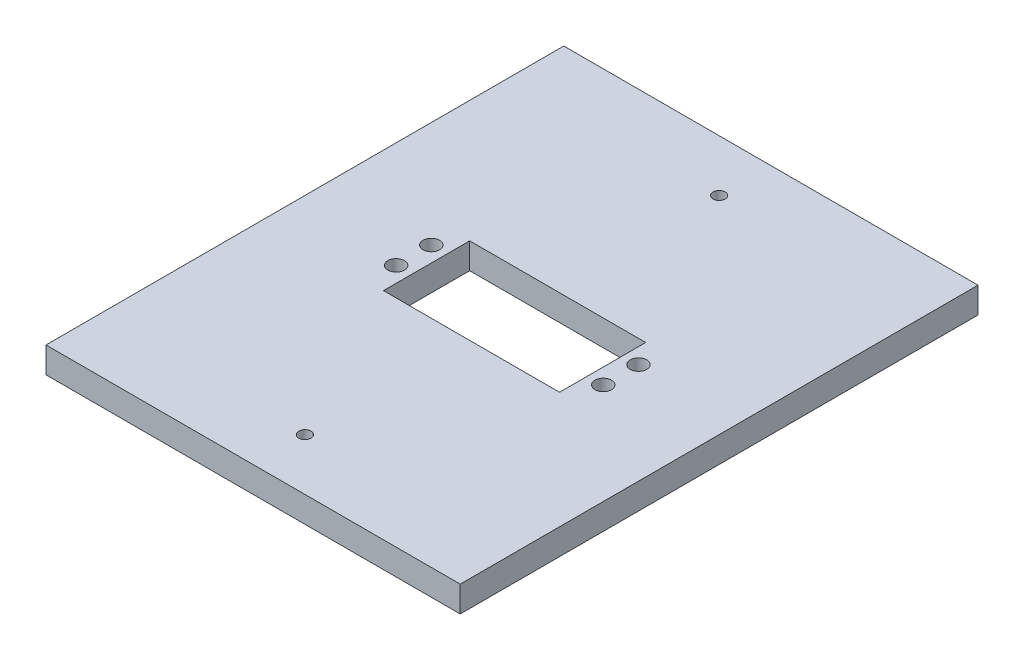
from build123d import *

# Parameters (mm, degrees)
SKETCH1_W           = 101.6
SKETCH1_H           = 127
BOSS_EXTRUDE1_DEPTH = 6.35
SKETCH2_R           = 2.032
SKETCH2_W           = 43.18
SKETCH2_H           = 21.1455
CUT_EXTRUDE1_DEPTH  = 7.35
SKETCH7_R           = 1.5
CUT_EXTRUDE2_DEPTH  = 7.35


with BuildPart() as part:
    # Sketch1 → Boss-Extrude1 (new body)
    with BuildSketch(Plane(origin=(0, 0, 0), x_dir=(1, 0, 0), z_dir=(0, 1, 0))):
        with Locations((134.62, 120.65)):
            Rectangle(SKETCH1_W, SKETCH1_H)
    extrude(amount=BOSS_EXTRUDE1_DEPTH)

    # Sketch2 → Cut-Extrude1 (cut, through all)
    with BuildSketch(Plane(origin=(0, 6.35, 0), x_dir=(1, 0, 0), z_dir=(0, 1, 0))):
        with Locations((109.855, 116.99875)):
            Circle(SKETCH2_R)
        with Locations((109.855, 125.63475)):
            Circle(SKETCH2_R)
        with Locations((160.655, 125.63475)):
            Circle(SKETCH2_R)
        with Locations((160.655, 116.99875)):
            Circle(SKETCH2_R)
        with Locations((135.255, 120.65)):
            Rectangle(SKETCH2_W, SKETCH2_H)
    extrude(amount=-CUT_EXTRUDE1_DEPTH, mode=Mode.SUBTRACT)

    # Sketch7 → Cut-Extrude2 (cut, through all)
    with BuildSketch(Plane(origin=(0, 6.35, 0), x_dir=(1, 0, 0), z_dir=(0, 1, 0))):
        with Locations((134.62, 171.45)):
            Circle(SKETCH7_R)
        with Locations((134.62, 69.85)):
            Circle(SKETCH7_R)
    extrude(amount=-CUT_EXTRUDE2_DEPTH, mode=Mode.SUBTRACT)


solid = part.part
